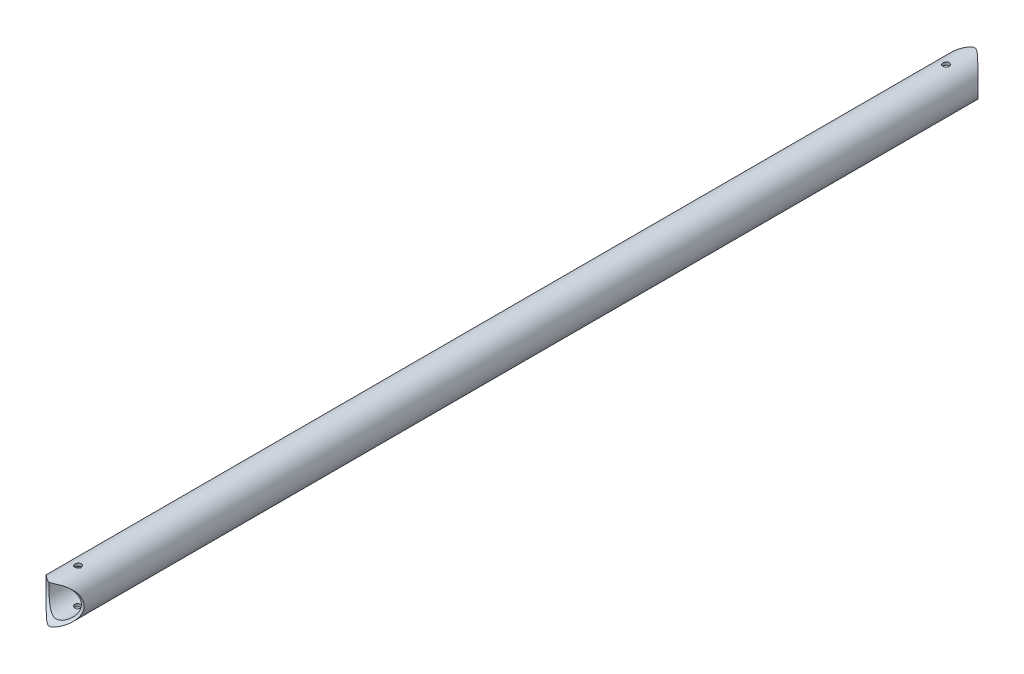
from build123d import *

# Parameters (mm, degrees)
SKETCH1_R               = 9.36
SKETCH1_R_2             = 7.99
EXTRUDE1_DEPTH          = 457.2
SKETCH2_R               = 9.525
CUT_EXTRUDE1_DEPTH      = 10.36
CUT_EXTRUDE1_DEPTH_BACK = 10.36
SKETCH3_R               = 9.525
CUT_EXTRUDE2_DEPTH      = 10.3600001
CUT_EXTRUDE2_DEPTH_BACK = 10.3600001
SKETCH5_R               = 1.55
CUT_EXTRUDE3_DEPTH      = 10.3600001
CUT_EXTRUDE3_DEPTH_BACK = 10.3600001


with BuildPart() as part:
    # Sketch1 → Extrude1 (new body)
    with BuildSketch(Plane.XY):
        Circle(SKETCH1_R)
        Circle(SKETCH1_R_2, mode=Mode.SUBTRACT)
    extrude(amount=EXTRUDE1_DEPTH)

    # Sketch2 → Cut-Extrude1 (cut, two sides)
    with BuildSketch(Plane(origin=(0, 0, 0), x_dir=(0, 0, -1), z_dir=(1, 0, 0))) as cut_extrude1_sk:
        Circle(SKETCH2_R)
    extrude(amount=CUT_EXTRUDE1_DEPTH, mode=Mode.SUBTRACT)
    extrude(cut_extrude1_sk.sketch, amount=-CUT_EXTRUDE1_DEPTH_BACK, mode=Mode.SUBTRACT)

    # Sketch3 → Cut-Extrude2 (cut, two sides)
    with BuildSketch(Plane(origin=(0, 0, 0), x_dir=(0, 0, -1), z_dir=(1, 0, 0))) as cut_extrude2_sk:
        with Locations((-457.2, 0)):
            Circle(SKETCH3_R)
    extrude(amount=CUT_EXTRUDE2_DEPTH, mode=Mode.SUBTRACT)
    extrude(cut_extrude2_sk.sketch, amount=-CUT_EXTRUDE2_DEPTH_BACK, mode=Mode.SUBTRACT)

    # Sketch5 → Cut-Extrude3 (cut, two sides)
    with BuildSketch(Plane(origin=(0, 0, 0), x_dir=(1, 0, 0), z_dir=(0, 1, 0))) as cut_extrude3_sk:
        with Locations((0, -441.33)):
            Circle(SKETCH5_R)
        with Locations((0, -15.88)):
            Circle(SKETCH5_R)
    extrude(amount=CUT_EXTRUDE3_DEPTH, mode=Mode.SUBTRACT)
    extrude(cut_extrude3_sk.sketch, amount=-CUT_EXTRUDE3_DEPTH_BACK, mode=Mode.SUBTRACT)


solid = part.part
